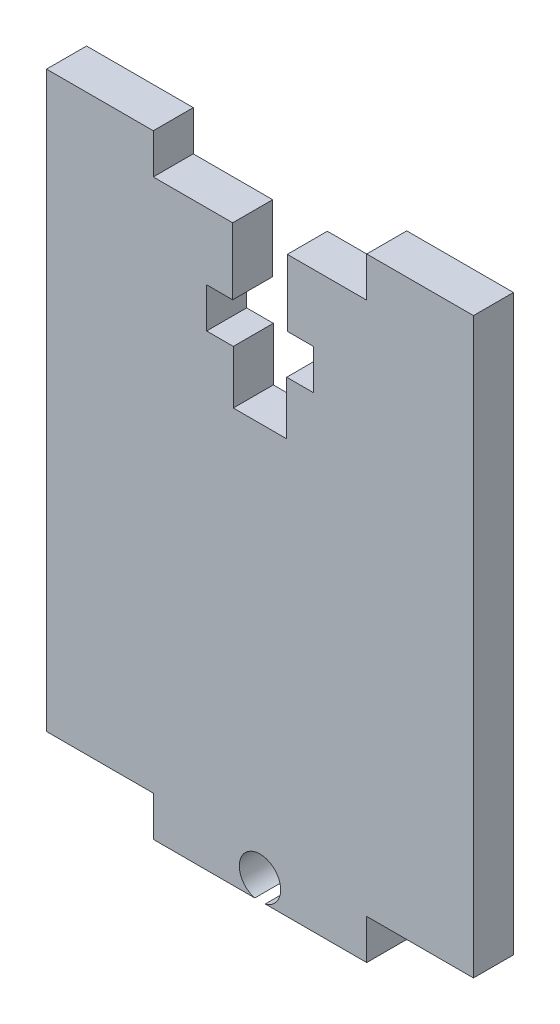
from build123d import *

# Parameters (mm, degrees)
EXTRUDE_1_DEPTH = 3


with BuildPart() as part:
    # 草图2 → 凸台-拉伸1 (new body)
    with BuildSketch(Plane.XY):
        with BuildLine():
            Line((2.047890023, 48.855305477), (8, 48.855305477))
            Line((8, 48.855305477), (8, 51.855305477))
            Line((8, 51.855305477), (16, 51.855305477))
            Line((16, 51.855305477), (16, 8.855305477))
            Line((16, 8.855305477), (8, 8.855305477))
            Line((8, 8.855305477), (8, 5.855305477))
            Line((8, 5.855305477), (0.390512484, 5.855305477))
            ThreePointArc((0.390512484, 5.855305477), (0, 8.905305477), (-0.390512484, 5.855305477))
            Line((-0.390512484, 5.855305477), (-8, 5.855305477))
            Line((-8, 5.855305477), (-8, 8.855305477))
            Line((-8, 8.855305477), (-16, 8.855305477))
            Line((-16, 8.855305477), (-16, 51.855305477))
            Line((-16, 51.855305477), (-8, 51.855305477))
            Line((-8, 51.855305477), (-8, 48.855305477))
            Line((-8, 48.855305477), (-2.047890023, 48.855305477))
            Line((-2.047890023, 48.855305477), (-2.047890023, 43.855305477))
            Line((-2.047890023, 43.855305477), (-4, 43.855305477))
            Line((-4, 43.855305477), (-4, 40.855305477))
            Line((-4, 40.855305477), (-2, 40.855305477))
            Line((-2, 40.855305477), (-2, 36.855305477))
            Line((-2, 36.855305477), (2, 36.855305477))
            Line((2, 36.855305477), (2, 40.855305477))
            Line((2, 40.855305477), (4, 40.855305477))
            Line((4, 40.855305477), (4, 43.855305477))
            Line((4, 43.855305477), (2.047890023, 43.855305477))
            Line((2.047890023, 43.855305477), (2.047890023, 48.855305477))
        make_face()
    extrude(amount=EXTRUDE_1_DEPTH)


solid = part.part
